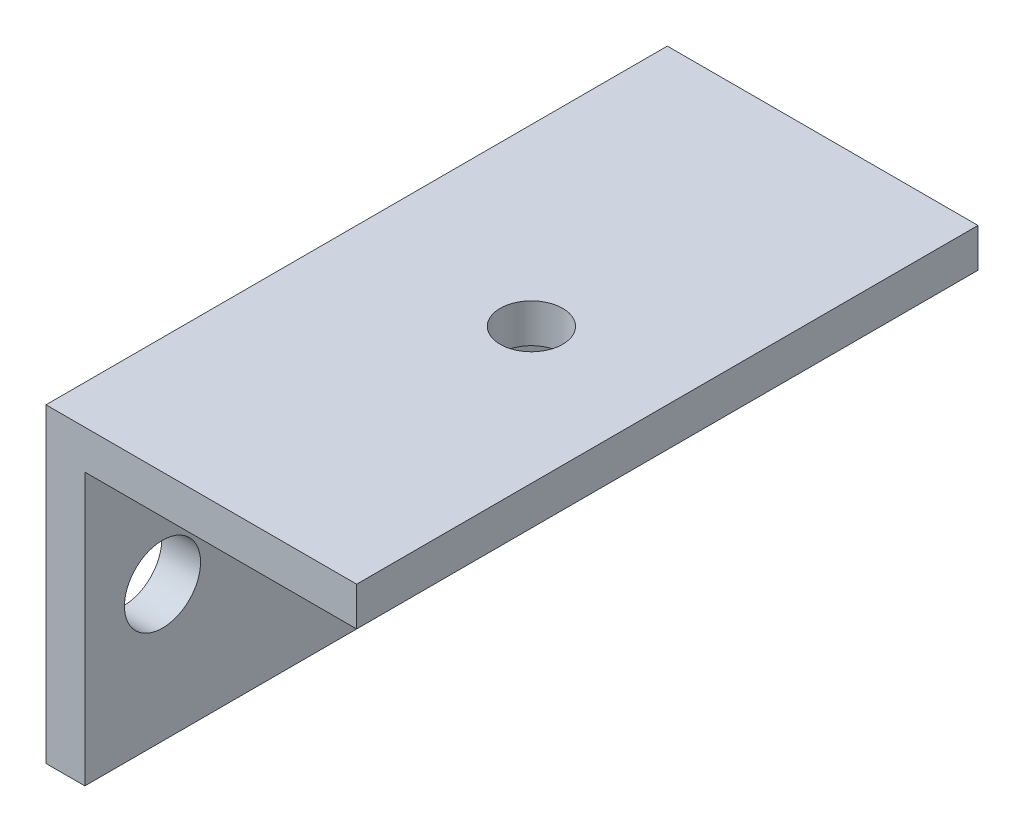
from build123d import *

# Parameters (mm, degrees)
BOSS_EXTRUDE1_DEPTH    = 50.8
SKETCH6_R              = 3.1115
CUT_EXTRUDE1_DEPTH     = 4.175
F_10_CLEARANCE_HOLE2_D = 5.1054


with BuildPart() as part:
    # Sketch3 → Boss-Extrude1 (new body)
    with BuildSketch(Plane.XY):
        Polygon((0, 0), (0, 25.4), (25.4, 25.4), (25.4, 22.225), (3.175, 22.225), (3.175, 0), align=None)
    extrude(amount=BOSS_EXTRUDE1_DEPTH)

    # Sketch6 → Cut-Extrude1 (cut, through all)
    with BuildSketch(Plane(origin=(3.175, 0, 0), x_dir=(0, 0, -1), z_dir=(1, 0, 0))):
        with Locations((-44.45, 11.1125)):
            Circle(SKETCH6_R)
        with Locations((-6.35, 11.1125)):
            Circle(SKETCH6_R)
    extrude(amount=-CUT_EXTRUDE1_DEPTH, mode=Mode.SUBTRACT)

    # #10 Clearance Hole2 (through all)
    with Locations(Plane(origin=(0, 22.225, 0), x_dir=(-1, 0, 0), z_dir=(0, -1, 0))):
        with Locations((-14.2875, -25.4)):
            Hole(F_10_CLEARANCE_HOLE2_D / 2)


solid = part.part
